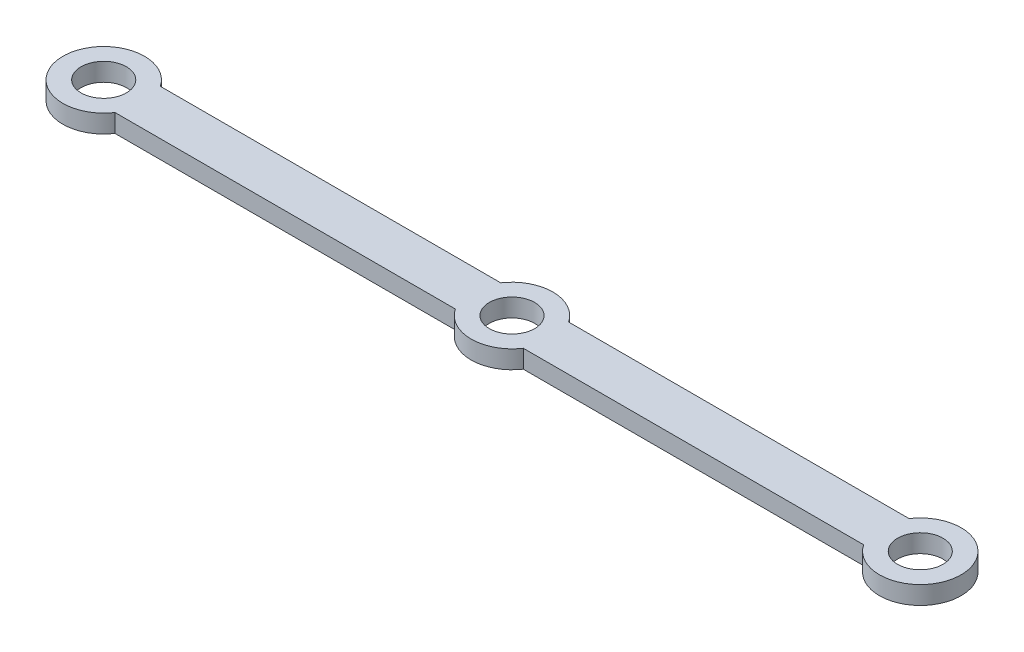
from build123d import *

# Parameters (mm, degrees)
SKETCH1_R           = 2.5
BOSS_EXTRUDE1_DEPTH = 2


with BuildPart() as part:
    # Sketch1 → Boss-Extrude1 (new body)
    with BuildSketch(Plane(origin=(0, 0, 0), x_dir=(1, 0, 0), z_dir=(0, 1, 0))):
        with BuildLine():
            Line((3.741657387, -2.5), (41.258342613, -2.5))
            ThreePointArc((41.258342613, -2.5), (45, -4.5), (48.741657387, -2.5))
            Line((48.741657387, -2.5), (86.258342613, -2.5))
            ThreePointArc((86.258342613, -2.5), (94.5, 0), (86.258342613, 2.5))
            Line((86.258342613, 2.5), (48.741657387, 2.5))
            ThreePointArc((48.741657387, 2.5), (45, 4.5), (41.258342613, 2.5))
            Line((41.258342613, 2.5), (3.741657387, 2.5))
            ThreePointArc((3.741657387, 2.5), (-4.5, 0), (3.741657387, -2.5))
        make_face()
        Circle(SKETCH1_R, mode=Mode.SUBTRACT)
        with Locations((45, 0)):
            Circle(SKETCH1_R, mode=Mode.SUBTRACT)
        with Locations((90, 0)):
            Circle(SKETCH1_R, mode=Mode.SUBTRACT)
    extrude(amount=BOSS_EXTRUDE1_DEPTH)


solid = part.part
